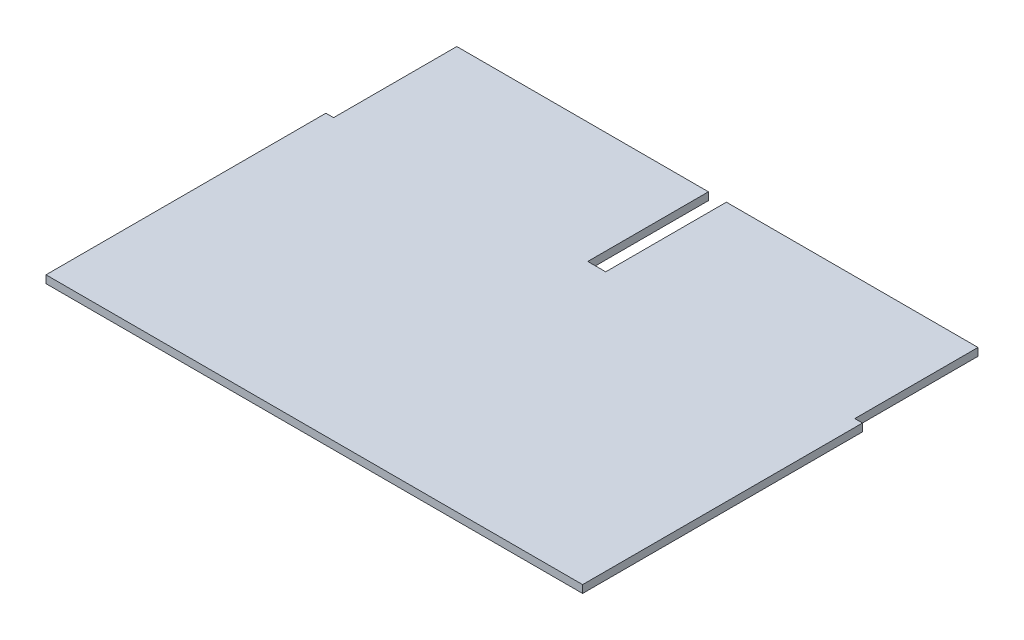
from build123d import *

# Parameters (mm, degrees)
SKETCH1_W           = 9.8
SKETCH1_H           = 4.7
SKETCH1_H_2         = 0.1
SKETCH1_W_2         = 0.1
SKETCH1_H_3         = 10.9
SKETCH1_W_3         = 0.2
BOSS_EXTRUDE1_DEPTH = 0.3


with BuildPart() as part:
    # Sketch1 → Boss-Extrude1 (new body)
    with BuildSketch(Plane(origin=(0, 0, 0), x_dir=(1, 0, 0), z_dir=(0, 1, 0))):
        with Locations((-5.25, 13.35)):
            Rectangle(SKETCH1_W, SKETCH1_H)
        with Locations((5.25, 13.35)):
            Rectangle(SKETCH1_W, SKETCH1_H)
        with Locations((-5.25, 10.95)):
            Rectangle(SKETCH1_W, SKETCH1_H_2)
        with Locations((5.25, 10.95)):
            Rectangle(SKETCH1_W, SKETCH1_H_2)
        Polygon((-0.35, 11), (-0.35, 10.9), (0.35, 10.9), (0.35, 11), (0.25, 11), (-0.25, 11), align=None)
        Polygon((-10.15, 10.9), (-10.15, 0), (10.15, 0), (10.15, 10.9), (0.35, 10.9), (-0.35, 10.9), align=None)
        with Locations((-10.2, 5.45)):
            Rectangle(SKETCH1_W_2, SKETCH1_H_3)
        with Locations((-10.35, 5.45)):
            Rectangle(SKETCH1_W_3, SKETCH1_H_3)
        with Locations((10.35, 5.45)):
            Rectangle(SKETCH1_W_3, SKETCH1_H_3)
        with Locations((10.2, 5.45)):
            Rectangle(SKETCH1_W_2, SKETCH1_H_3)
    extrude(amount=BOSS_EXTRUDE1_DEPTH)


solid = part.part
